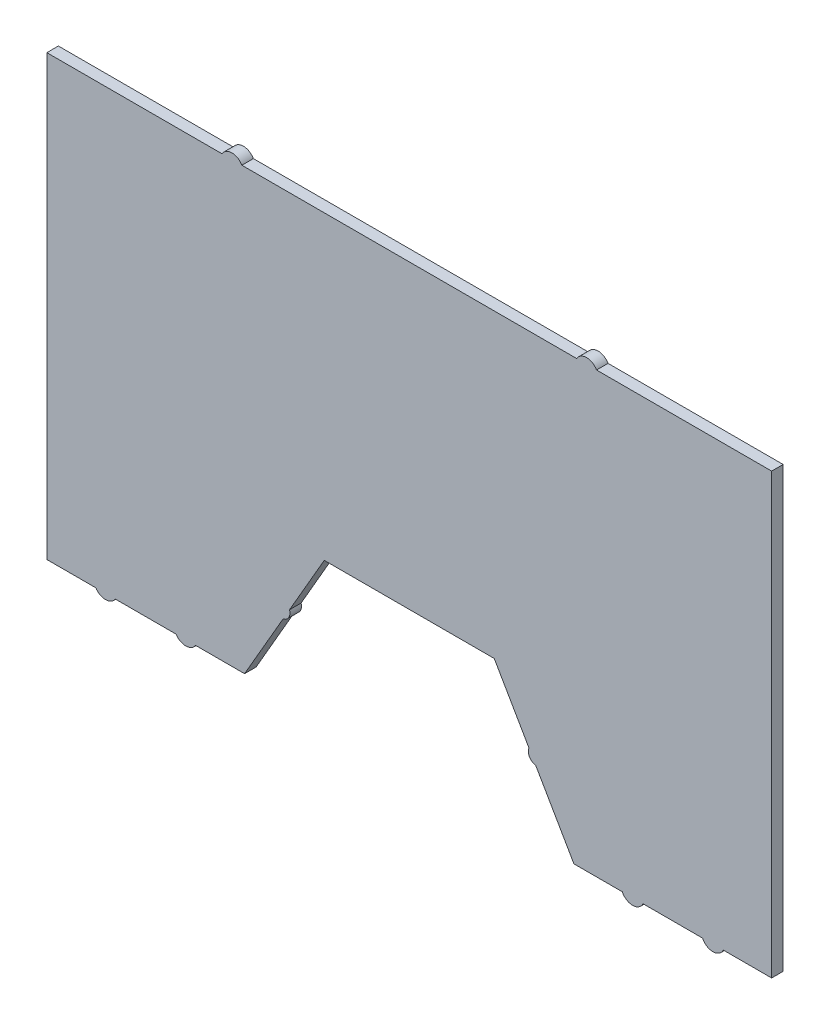
from build123d import *

# Parameters (mm, degrees)
BOSS_EXTRUDE1_DEPTH = 5


with BuildPart() as part:
    # Sketch1 → Boss-Extrude1 (new body)
    with BuildSketch(Plane.XY):
        with BuildLine():
            Line((-114.983429669, -41.595326503), (-88.552733296, -41.595326503))
            ThreePointArc((-88.552733296, -41.595326503), (-84.32255291, -43.929698265), (-80.092372525, -41.595326503))
            Line((-80.092372525, -41.595326503), (-58.788151834, -41.595326503))
            Line((-58.788151834, -41.595326503), (-42.04280008, -12.591526475))
            ThreePointArc((-42.04280008, -12.591526475), (-39.562725839, -10.795911883), (-39.247715108, -7.750297292))
            Line((-39.247715108, -7.750297292), (-24.147135682, 18.404673497))
            Line((-24.147135682, 18.404673497), (49.753698774, 18.404673497))
            Line((49.753698774, 18.404673497), (64.843098402, -7.730933315))
            ThreePointArc((64.843098402, -7.730933315), (65.07717154, -10.998946288), (67.790317225, -12.835666057))
            Line((67.790317225, -12.835666057), (84.394714925, -41.595326503))
            Line((84.394714925, -41.595326503), (105.408163945, -41.595326503))
            ThreePointArc((105.408163945, -41.595326503), (109.928281546, -44.457912909), (114.448399147, -41.595326503))
            Line((114.448399147, -41.595326503), (140.300890001, -41.595326503))
            ThreePointArc((140.300890001, -41.595326503), (144.821007602, -44.457912909), (149.341125203, -41.595326503))
            Line((149.341125203, -41.595326503), (170.354574223, -41.595326503))
            Line((170.354574223, -41.595326503), (170.354574223, 149.258117984))
            Line((170.354574223, 149.258117984), (94.234420776, 149.258117984))
            ThreePointArc((94.234420776, 149.258117984), (89.904293757, 151.758117984), (85.574166738, 149.258117984))
            Line((85.574166738, 149.258117984), (-59.967510158, 149.258117984))
            ThreePointArc((-59.967510158, 149.258117984), (-64.297637177, 151.758117984), (-68.627764196, 149.258117984))
            Line((-68.627764196, 149.258117984), (-144.748011131, 149.258117984))
            Line((-144.748011131, 149.258117984), (-144.748011131, -41.595326503))
            Line((-144.748011131, -41.595326503), (-123.44379044, -41.595326503))
            ThreePointArc((-123.44379044, -41.595326503), (-119.213610054, -43.929698265), (-114.983429669, -41.595326503))
        make_face()
    extrude(amount=BOSS_EXTRUDE1_DEPTH)


solid = part.part
